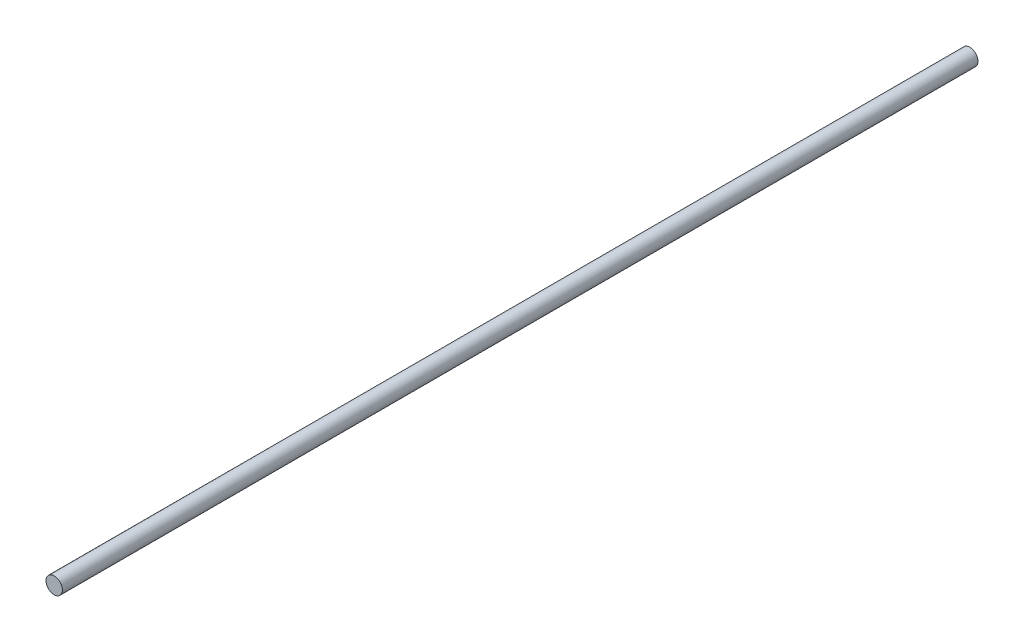
from build123d import *

# Parameters (mm, degrees)
ESQUISSE1_R        = 4
BOSS_EXTRU_1_DEPTH = 448


with BuildPart() as part:
    # Esquisse1 → Boss.-Extru.1 (new body)
    with BuildSketch(Plane.XY):
        Circle(ESQUISSE1_R)
    extrude(amount=BOSS_EXTRU_1_DEPTH)


solid = part.part
